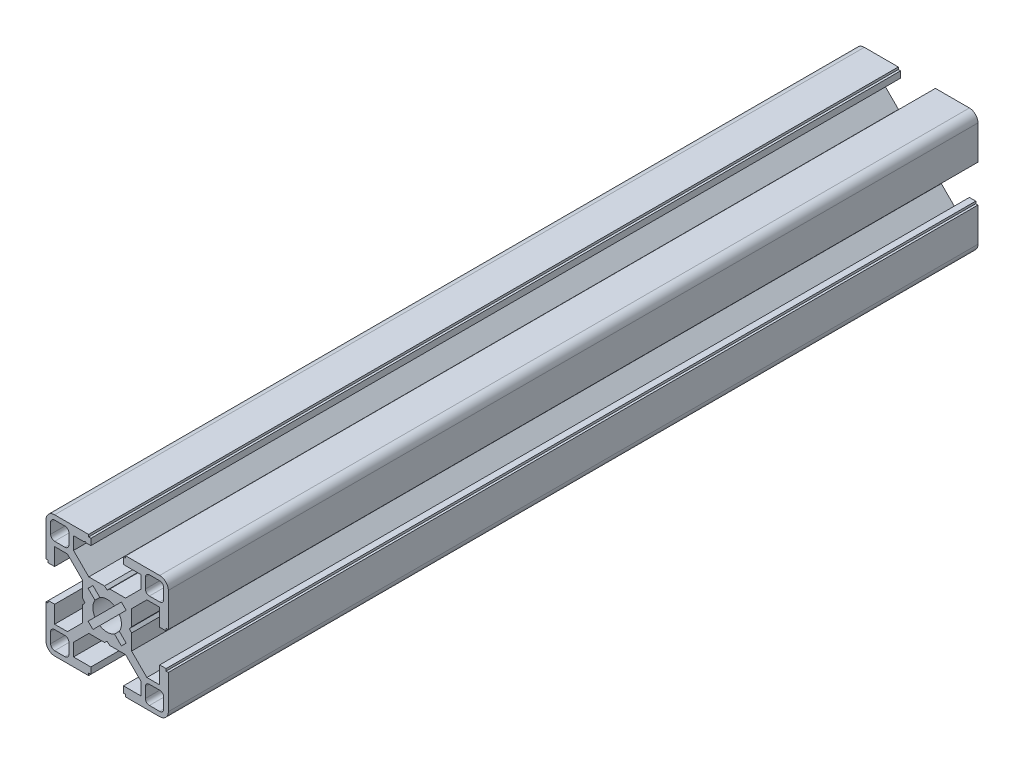
from build123d import *

# Parameters (mm, degrees)
BOSS_EXTRUDE1_DEPTH     = 198.6
CUT_EXTRUDE1_DEPTH      = 1
CUT_EXTRUDE1_DEPTH_BACK = 199.6


with BuildPart() as part:
    # Sketch4 → Boss-Extrude1 (new body)
    with BuildSketch(Plane.XY):
        with BuildLine():
            Line((0, -5.45), (0.655464476, -6))
            Line((0.655464476, -6), (4.504469158, -6))
            Line((4.504469158, -6), (8.25, -9.745530842))
            Line((8.25, -9.745530842), (8.25, -12.885))
            Line((8.25, -12.885), (4, -12.885))
            Line((4, -12.885), (4, -14.45))
            Line((4, -14.45), (4.55, -14.45))
            Line((4.55, -14.45), (4.55, -15))
            Line((4.55, -15), (12.885, -15))
            ThreePointArc((12.885, -15), (14.380530842, -14.380530842), (15, -12.885))
            Line((15, -12.885), (15, -4.55))
            Line((15, -4.55), (14.45, -4.55))
            Line((14.45, -4.55), (14.45, -4))
            Line((14.45, -4), (12.885, -4))
            Line((12.885, -4), (12.885, -8.25))
            Line((12.885, -8.25), (9.745530842, -8.25))
            Line((9.745530842, -8.25), (6, -4.504469158))
            Line((6, -4.504469158), (6, -0.655464476))
            Line((6, -0.655464476), (5.45, 0))
            Line((5.45, 0), (3.5, 0))
            ThreePointArc((3.5, 0), (3.371433308, -0.939913534), (2.995178599, -1.81077474))
            Line((2.995178599, -1.81077474), (4.675743591, -3.491339732))
            Line((4.675743591, -3.491339732), (3.491339732, -4.675743591))
            Line((3.491339732, -4.675743591), (1.81077474, -2.995178599))
            ThreePointArc((1.81077474, -2.995178599), (0.939913534, -3.371433308), (0, -3.5))
            Line((0, -3.5), (0, -5.45))
        make_face()
        with BuildLine():
            Line((9.375, -10.365), (9.375, -12.885))
            ThreePointArc((9.375, -12.885), (9.664964287, -13.585035713), (10.365, -13.875))
            Line((10.365, -13.875), (12.885, -13.875))
            ThreePointArc((12.885, -13.875), (13.585035713, -13.585035713), (13.875, -12.885))
            Line((13.875, -12.885), (13.875, -10.365))
            ThreePointArc((13.875, -10.365), (13.585035713, -9.664964287), (12.885, -9.375))
            Line((12.885, -9.375), (10.365, -9.375))
            ThreePointArc((10.365, -9.375), (9.664964287, -9.664964287), (9.375, -10.365))
        make_face(mode=Mode.SUBTRACT)
    extrude(amount=BOSS_EXTRUDE1_DEPTH)

    # Mirror1: part across plane


with BuildPart() as part_1:
    add(part.part)
    add(part.part.mirror(Plane(origin=(0, 0, 0), x_dir=(0, 0, 1), z_dir=(1, 0, 0))))

    # Mirror2: part across plane


with BuildPart() as part_2:
    add(part_1.part)
    add(part_1.part.mirror(Plane.ZX))

    # Sketch5 → Cut-Extrude1 (cut, two sides)
    with BuildSketch(Plane.XY.offset(198.6)) as cut_extrude1_sk:
        Polygon((-5.675, 12.885), (-5.4, 13.16), (-5.125, 12.885), align=None)
    extrude(amount=CUT_EXTRUDE1_DEPTH, mode=Mode.SUBTRACT)
    extrude(cut_extrude1_sk.sketch, amount=-CUT_EXTRUDE1_DEPTH_BACK, mode=Mode.SUBTRACT)


solid = part_2.part
